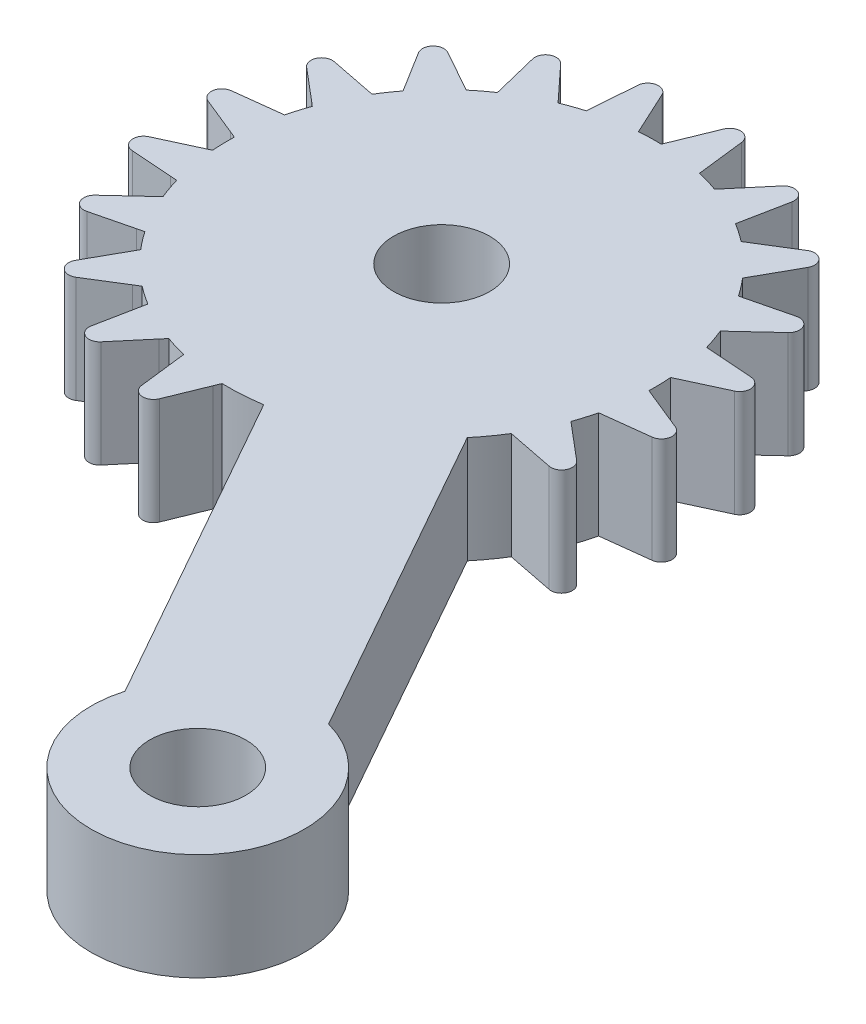
from build123d import *

# Parameters (mm, degrees)
BOSS_EXTRUDE1_DEPTH        = 5
F_4_5_4_5_DIAMETER_HOLE1_D = 4.5


with BuildPart() as part:
    # Sketch1 → Boss-Extrude1 (new body)
    with BuildSketch(Plane(origin=(0, -74, 0), x_dir=(1, 0, 0), z_dir=(0, 1, 0))):
        with BuildLine():
            Line((9.792858273, -22.023664764), (18.163987442, -36.890703242))
            ThreePointArc((18.163987442, -36.890703242), (25.418865109, -42.641693781), (24.263539525, -33.456250682))
            Line((24.263539525, -33.456250682), (15.892410356, -18.589212204))
            ThreePointArc((15.892410356, -18.589212204), (16.346796769, -18.007963525), (16.757092444, -17.394795929))
            Line((16.757092444, -17.394795929), (18.965700238, -17.831555144))
            ThreePointArc((18.965700238, -17.831555144), (19.514808102, -17.55458812), (19.379909826, -16.954560925))
            Line((19.379909826, -16.954560925), (17.910889228, -15.715657441))
            Line((17.910889228, -15.715657441), (17.664910308, -15.504807423))
            ThreePointArc((17.664910308, -15.504807423), (17.827013037, -15.010242888), (17.963165175, -14.507914341))
            Line((17.963165175, -14.507914341), (20.19864203, -14.240799695))
            ThreePointArc((20.19864203, -14.240799695), (20.635287125, -13.80770474), (20.32157264, -13.278730827))
            Line((20.32157264, -13.278730827), (18.541608797, -12.554415925))
            Line((18.541608797, -12.554415925), (18.242512703, -12.429897308))
            ThreePointArc((18.242512703, -12.429897308), (18.243852713, -11.909445986), (18.218113034, -11.389629824))
            Line((18.218113034, -11.389629824), (20.261634899, -10.444788361))
            ThreePointArc((20.261634899, -10.444788361), (20.543075361, -9.897959827), (20.081253227, -9.491818847))
            Line((20.081253227, -9.491818847), (18.164581401, -9.352993516))
            Line((18.164581401, -9.352993516), (17.841645743, -9.32699505))
            ThreePointArc((17.841645743, -9.32699505), (17.682091866, -8.831602343), (17.496979948, -8.345181793))
            Line((17.496979948, -8.345181793), (19.148512665, -6.815101178))
            ThreePointArc((19.148512665, -6.815101178), (19.247199139, -6.208066452), (18.682475725, -5.964514314))
            Line((18.682475725, -5.964514314), (16.816713109, -6.424767746))
            Line((16.816713109, -6.424767746), (16.501549079, -6.499834341))
            ThreePointArc((16.501549079, -6.499834341), (16.196719559, -6.077992739), (15.870355447, -5.672582033))
            Line((15.870355447, -5.672582033), (16.968235486, -3.707037218))
            ThreePointArc((16.968235486, -3.707037218), (16.874507855, -3.099217089), (16.262162222, -3.042094373))
            Line((16.262162222, -3.042094373), (14.62994266, -4.056373754))
            Line((14.62994266, -4.056373754), (14.353400709, -4.22515737))
            ThreePointArc((14.353400709, -4.22515737), (13.933134384, -3.918159668), (13.497464871, -3.633443231))
            Line((13.497464871, -3.633443231), (13.934224085, -1.424835437))
            ThreePointArc((13.934224085, -1.424835437), (13.657257061, -0.875727573), (13.057229867, -1.010625848))
            Line((13.057229867, -1.010625848), (11.818326382, -2.479646446))
            Line((11.818326382, -2.479646446), (11.607476364, -2.725625367))
            ThreePointArc((11.607476364, -2.725625367), (11.112911829, -2.563522638), (10.610583282, -2.427370499))
            Line((10.610583282, -2.427370499), (10.343468637, -0.191893645))
            ThreePointArc((10.343468637, -0.191893645), (9.910373682, 0.24475145), (9.381399768, -0.068963034))
            Line((9.381399768, -0.068963034), (8.657084866, -1.848926878))
            Line((8.657084866, -1.848926878), (8.532566249, -2.148022972))
            ThreePointArc((8.532566249, -2.148022972), (8.012114927, -2.146682961), (7.492298765, -2.17242264))
            Line((7.492298765, -2.17242264), (6.547457302, -0.128900776))
            ThreePointArc((6.547457302, -0.128900776), (6.000628768, 0.152539686), (5.594487788, -0.309282448))
            Line((5.594487788, -0.309282448), (5.455662457, -2.225954274))
            Line((5.455662457, -2.225954274), (5.429663991, -2.548889932))
            ThreePointArc((5.429663991, -2.548889932), (4.934271284, -2.708443809), (4.447850734, -2.893555727))
            Line((4.447850734, -2.893555727), (2.917770119, -1.24202301))
            ThreePointArc((2.917770119, -1.24202301), (2.310735394, -1.143336536), (2.067183255, -1.70805995))
            Line((2.067183255, -1.70805995), (2.527436687, -3.573822566))
            Line((2.527436687, -3.573822566), (2.602503283, -3.888986596))
            ThreePointArc((2.602503283, -3.888986596), (2.18066168, -4.193816116), (1.775250975, -4.520180228))
            Line((1.775250975, -4.520180228), (-0.19029384, -3.422300189))
            ThreePointArc((-0.19029384, -3.422300189), (-0.79811397, -3.51602782), (-0.855236686, -4.128373453))
            Line((-0.855236686, -4.128373453), (0.159042695, -5.760593015))
            Line((0.159042695, -5.760593015), (0.327826311, -6.037134965))
            ThreePointArc((0.327826311, -6.037134965), (0.020828609, -6.457401291), (-0.263887828, -6.893070804))
            Line((-0.263887828, -6.893070804), (-2.472495622, -6.45631159))
            ThreePointArc((-2.472495622, -6.45631159), (-3.021603486, -6.733278614), (-2.88670521, -7.333305808))
            Line((-2.88670521, -7.333305808), (-1.417684612, -8.572209293))
            Line((-1.417684612, -8.572209293), (-1.171705692, -8.783059311))
            ThreePointArc((-1.171705692, -8.783059311), (-1.333808421, -9.277623846), (-1.469960559, -9.779952393))
            Line((-1.469960559, -9.779952393), (-3.705437414, -10.047067038))
            ThreePointArc((-3.705437414, -10.047067038), (-4.142082509, -10.480161993), (-3.828368024, -11.009135907))
            Line((-3.828368024, -11.009135907), (-2.048404181, -11.733450809))
            Line((-2.048404181, -11.733450809), (-1.749308087, -11.857969426))
            ThreePointArc((-1.749308087, -11.857969426), (-1.750648097, -12.378420747), (-1.724908418, -12.89823691))
            Line((-1.724908418, -12.89823691), (-3.768430283, -13.843078373))
            ThreePointArc((-3.768430283, -13.843078373), (-4.049870744, -14.389906907), (-3.588048611, -14.796047887))
            Line((-3.588048611, -14.796047887), (-1.671376785, -14.934873217))
            Line((-1.671376785, -14.934873217), (-1.348441127, -14.960871684))
            ThreePointArc((-1.348441127, -14.960871684), (-1.188887249, -15.45626439), (-1.003775332, -15.942684941))
            Line((-1.003775332, -15.942684941), (-2.655308048, -17.472765555))
            ThreePointArc((-2.655308048, -17.472765555), (-2.753994523, -18.079800281), (-2.189271109, -18.32335242))
            Line((-2.189271109, -18.32335242), (-0.323508493, -17.863098988))
            Line((-0.323508493, -17.863098988), (-0.008344463, -17.788032392))
            ThreePointArc((-0.008344463, -17.788032392), (0.296485057, -18.209873994), (0.622849169, -18.6152847))
            Line((0.622849169, -18.6152847), (-0.47503087, -20.580829515))
            ThreePointArc((-0.47503087, -20.580829515), (-0.381303238, -21.188649645), (0.231042394, -21.245772361))
            Line((0.231042394, -21.245772361), (1.863261956, -20.23149298))
            Line((1.863261956, -20.23149298), (2.139803907, -20.062709363))
            ThreePointArc((2.139803907, -20.062709363), (2.560070232, -20.369707066), (2.995739745, -20.654423502))
            Line((2.995739745, -20.654423502), (2.558980531, -22.863031297))
            ThreePointArc((2.558980531, -22.863031297), (2.835947555, -23.412139161), (3.43597475, -23.277240885))
            Line((3.43597475, -23.277240885), (4.674878234, -21.808220287))
            Line((4.674878234, -21.808220287), (4.885728252, -21.562241367))
            ThreePointArc((4.885728252, -21.562241367), (5.380292787, -21.724344095), (5.882621334, -21.860496234))
            Line((5.882621334, -21.860496234), (6.149735979, -24.095973089))
            ThreePointArc((6.149735979, -24.095973089), (6.582830934, -24.532618183), (7.111804848, -24.218903699))
            Line((7.111804848, -24.218903699), (7.83611975, -22.438939856))
            Line((7.83611975, -22.438939856), (7.960638367, -22.139843762))
            ThreePointArc((7.960638367, -22.139843762), (8.879420123, -22.123890361), (9.792858273, -22.023664764))
        make_face()
    extrude(amount=-BOSS_EXTRUDE1_DEPTH)

    # Ø4.5 (4.5) Diameter Hole1 (through all)
    with Locations(Plane(origin=(0, -79, 0), x_dir=(-1, 0, 0), z_dir=(0, -1, 0))):
        with Locations((-22.965684708, -38.284870865), (-8.246602308, -12.143933367)):
            Hole(F_4_5_4_5_DIAMETER_HOLE1_D / 2)


solid = part.part
